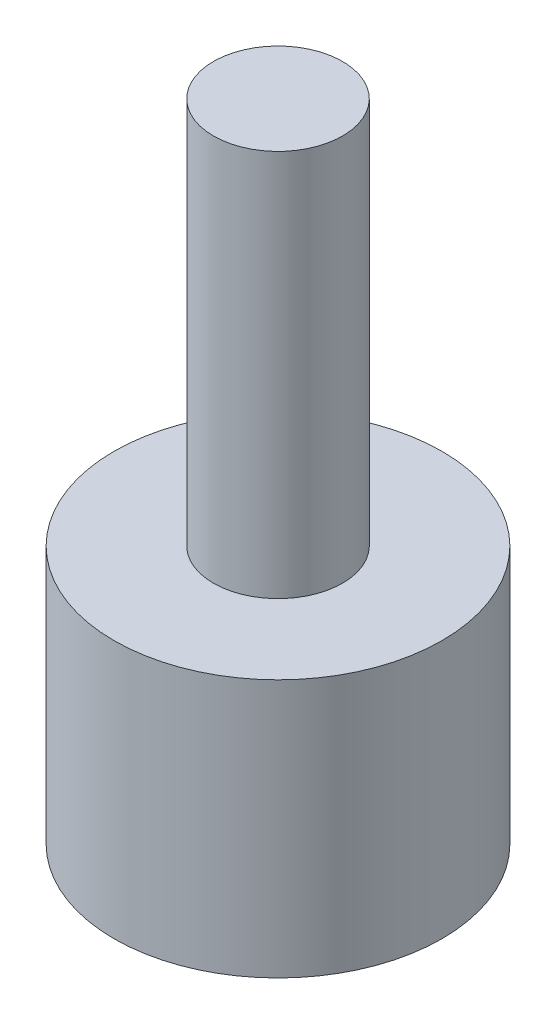
from build123d import *

# Parameters (mm, degrees)
SKETCH1_R           = 6.35
BOSS_EXTRUDE1_DEPTH = 10
SKETCH2_R           = 2.5
BOSS_EXTRUDE2_DEPTH = 15


with BuildPart() as part:
    # Sketch1 → Boss-Extrude1 (new body)
    with BuildSketch(Plane(origin=(0, 0, 0), x_dir=(1, 0, 0), z_dir=(0, 1, 0))):
        Circle(SKETCH1_R)
    extrude(amount=BOSS_EXTRUDE1_DEPTH)

    # Sketch2 → Boss-Extrude2 (add)
    with BuildSketch(Plane(origin=(0, 10, 0), x_dir=(1, 0, 0), z_dir=(0, 1, 0))):
        Circle(SKETCH2_R)
    extrude(amount=BOSS_EXTRUDE2_DEPTH)


solid = part.part
